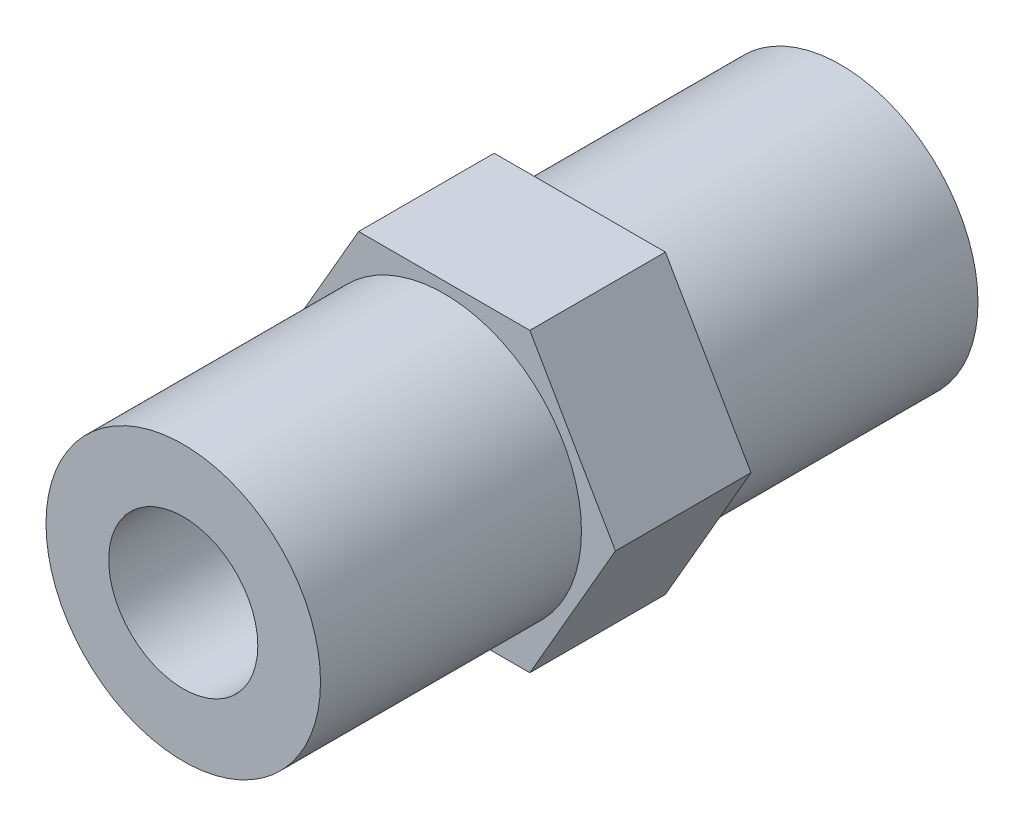
from build123d import *

# Parameters (mm, degrees)
SKETCH2_R           = 5.1435
BOSS_EXTRUDE1_DEPTH = 12.319
SKETCH3_R           = 2.794
CUT_EXTRUDE1_DEPTH  = 26.689340756
BOSS_EXTRUDE2_DEPTH = 2.54
SKETCH3_2_R         = 2.794
CUT_EXTRUDE2_DEPTH  = 27.058885436


with BuildPart() as part:
    # Sketch2 → Boss-Extrude1 (new, symmetric)
    with BuildSketch(Plane.XY):
        Circle(SKETCH2_R)
    extrude(amount=BOSS_EXTRUDE1_DEPTH, both=True)

    # Sketch3 → Cut-Extrude1 (cut, through all)
    with BuildSketch(Plane.XY.offset(12.319)):
        Circle(SKETCH3_R)
    extrude(amount=-CUT_EXTRUDE1_DEPTH, mode=Mode.SUBTRACT)

    # Sketch4 → Boss-Extrude2 (add, symmetric)
    with BuildSketch(Plane.XY):
        Polygon((3.207902433, 5.55625), (-3.207902433, 5.55625), (-6.415804866, 0), (-3.207902433, -5.55625), (3.207902433, -5.55625), (6.415804866, 0), align=None)
    extrude(amount=BOSS_EXTRUDE2_DEPTH, both=True)

    # Sketch3_2 → Cut-Extrude2 (cut, through all)
    with BuildSketch(Plane.XY.offset(12.319)):
        Circle(SKETCH3_2_R)
    extrude(amount=-CUT_EXTRUDE2_DEPTH, mode=Mode.SUBTRACT)


solid = part.part
